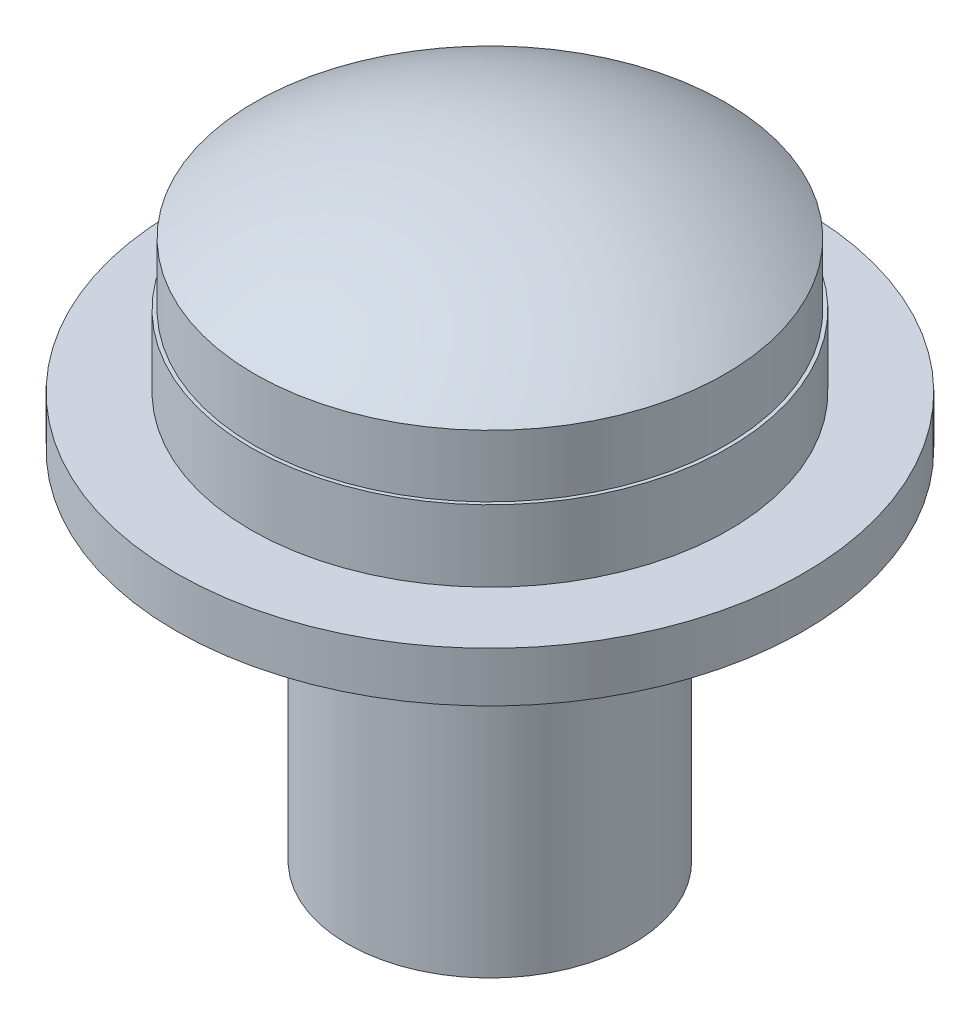
from build123d import *

# Parameters (mm, degrees)
SKETCH_1_R          = 4.4
EXTRUDE_1_DEPTH     = 0.7
SKETCH_2_R          = 3.35
EXTRUDE_2_DEPTH     = 1
SKETCH_3_R          = 3.4
EXTRUDE_3_DEPTH     = 1.9
SKETCH_4_R          = 10.526345736
SKETCH_4_R_2        = 3.3
CUT_EXTRUDE_1_DEPTH = 1
SKETCH_6_R          = 2
EXTRUDE_4_DEPTH     = 5


with BuildPart() as part:
    # 草图1 → 凸台-拉伸1 (new body)
    with BuildSketch(Plane(origin=(0, 0, 0), x_dir=(1, 0, 0), z_dir=(0, 1, 0))):
        Circle(SKETCH_1_R)
    extrude(amount=EXTRUDE_1_DEPTH)

    # 草图2 → 凸台-拉伸2 (add)
    with BuildSketch(Plane(origin=(0, 0.7, 0), x_dir=(1, 0, 0), z_dir=(0, 1, 0))):
        Circle(SKETCH_2_R)
    extrude(amount=EXTRUDE_2_DEPTH)

    # 草图3 → 凸台-拉伸3 (add)
    with BuildSketch(Plane(origin=(0, 1.7, 0), x_dir=(1, 0, 0), z_dir=(0, 1, 0))):
        Circle(SKETCH_3_R)
    extrude(amount=EXTRUDE_3_DEPTH)

    # 草图4 → 切除-拉伸1 (cut)
    with BuildSketch(Plane.XZ.offset(-1.7)):
        Circle(SKETCH_4_R)
        Circle(SKETCH_4_R_2, mode=Mode.SUBTRACT)
    extrude(amount=-CUT_EXTRUDE_1_DEPTH, mode=Mode.SUBTRACT)

    # 草图6 → 凸台-拉伸4 (add)
    with BuildSketch(Plane.XZ):
        Circle(SKETCH_6_R)
    extrude(amount=EXTRUDE_4_DEPTH)

    # 草图8 → 切除-旋转3 (revolve, cut)
    with BuildSketch(Plane(origin=(0, 0, 0), x_dir=(0, 0, -1), z_dir=(1, 0, 0))):
        with BuildLine():
            Line((0, 4.687391613), (0, 3.6))
            ThreePointArc((0, 3.6), (3.540607137, 2.39280141), (5.606264331, -0.72589827))
            Line((5.606264331, -0.72589827), (5.606264331, 4.687391613))
            Line((5.606264331, 4.687391613), (0, 4.687391613))
        make_face()
    revolve(axis=Axis((0, 3.6, 0), (0, -1, 0)), mode=Mode.SUBTRACT)


solid = part.part
